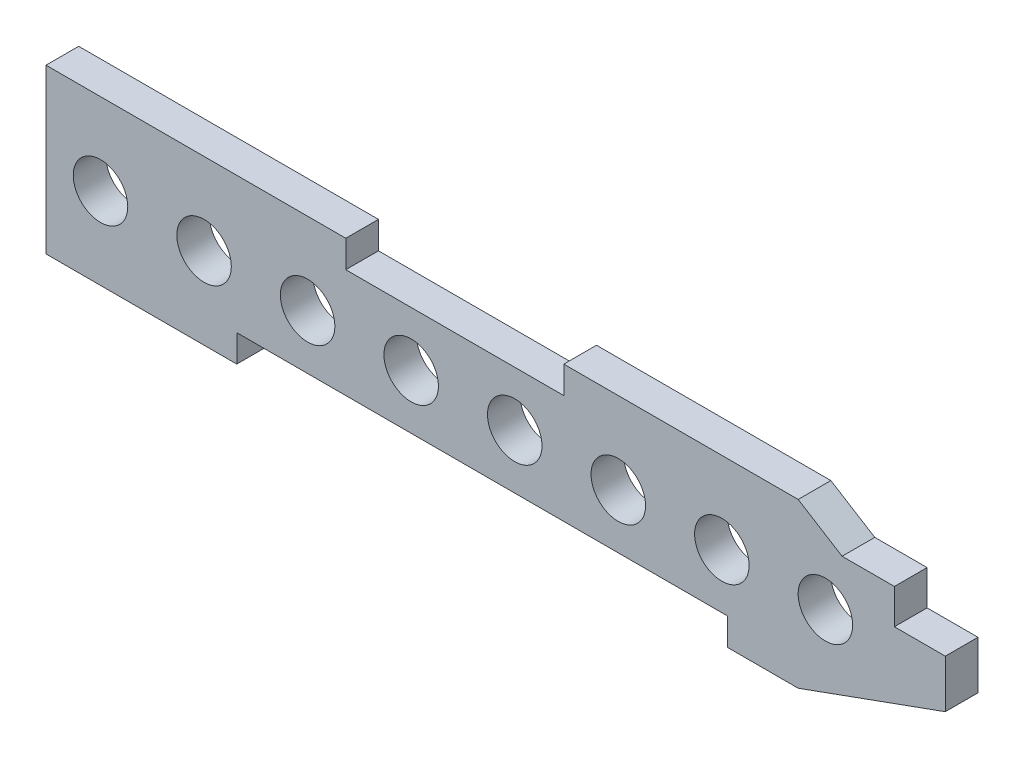
from build123d import *

# Parameters (mm, degrees)
SKETCH1_R           = 10
BOSS_EXTRUDE3_DEPTH = 12


with BuildPart() as part:
    # Sketch1 → Boss-Extrude3 (new body)
    with BuildSketch(Plane.XY):
        Polygon((-197.803002033, 35.875764478), (-197.803002033, -24.124235522), (-127.803002033, -24.124235522), (-127.803002033, -14.124235522), (52.196997967, -14.124235522), (52.196997967, -24.124235522), (78.206997967, -24.124235522), (132.196997967, -4.594235522), (132.196997967, 13.065764478), (113.516997967, 13.065764478), (113.516997967, 25.875764478), (94.316997967, 25.875764478), (78.206997967, 35.875764478), (-7.803002033, 35.875764478), (-7.803002033, 25.875764478), (-87.803002033, 25.875764478), (-87.803002033, 35.875764478), align=None)
        with Locations((-177.803002033, 5.875764478)):
            Circle(SKETCH1_R, mode=Mode.SUBTRACT)
        with Locations((-139.803002033, 5.875764478)):
            Circle(SKETCH1_R, mode=Mode.SUBTRACT)
        with Locations((-101.803002033, 5.875764478)):
            Circle(SKETCH1_R, mode=Mode.SUBTRACT)
        with Locations((-63.803002033, 5.875764478)):
            Circle(SKETCH1_R, mode=Mode.SUBTRACT)
        with Locations((-25.803002033, 5.875764478)):
            Circle(SKETCH1_R, mode=Mode.SUBTRACT)
        with Locations((12.196997967, 5.875764478)):
            Circle(SKETCH1_R, mode=Mode.SUBTRACT)
        with Locations((50.196997967, 5.875764478)):
            Circle(SKETCH1_R, mode=Mode.SUBTRACT)
        with Locations((88.196997967, 5.875764478)):
            Circle(SKETCH1_R, mode=Mode.SUBTRACT)
    extrude(amount=BOSS_EXTRUDE3_DEPTH)


solid = part.part
